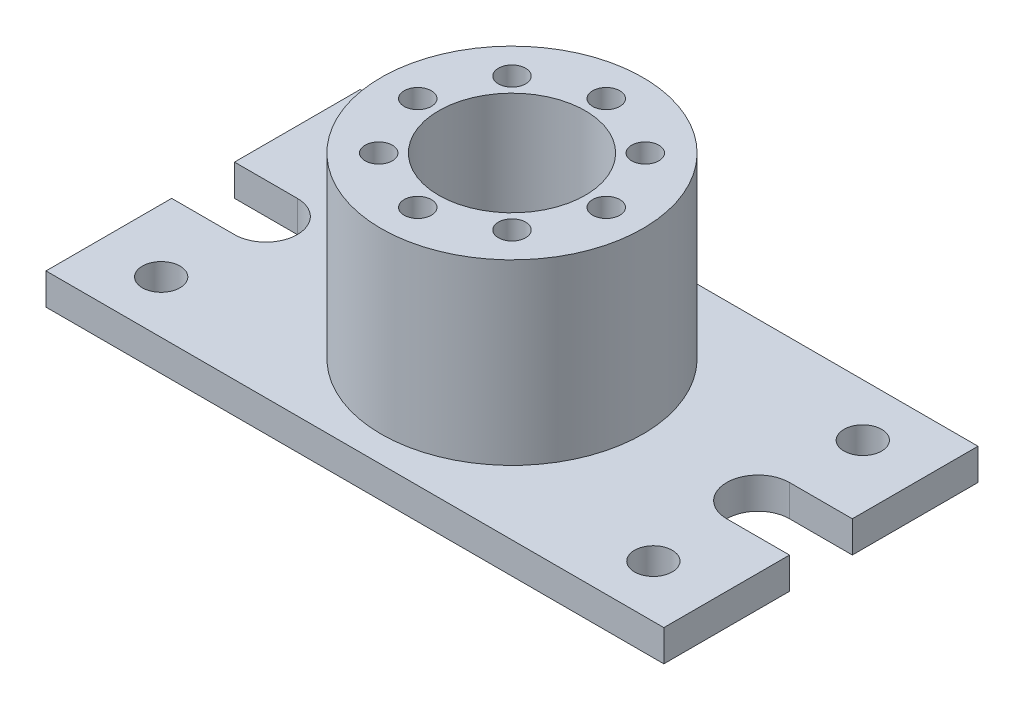
from build123d import *

# Parameters (mm, degrees)
SKETCH1_R           = 9
BOSS_EXTRUDE1_DEPTH = 15
SKETCH2_R           = 62.5
BOSS_EXTRUDE2_DEPTH = 85
SKETCH3_R           = 35
CUT_EXTRUDE1_DEPTH  = 101
SKETCH4_R           = 6.5
CUT_EXTRUDE2_DEPTH  = 50


with BuildPart() as part:
    # Sketch1 → Boss-Extrude1 (new body)
    with BuildSketch(Plane(origin=(0, 0, 0), x_dir=(1, 0, 0), z_dir=(0, 1, 0))):
        with BuildLine():
            Line((-147.5, -15), (-147.5, -75))
            Line((-147.5, -75), (147.5, -75))
            Line((147.5, -75), (147.5, -15))
            Line((147.5, -15), (117.5, -15))
            ThreePointArc((117.5, -15), (102.5, 0), (117.5, 15))
            Line((117.5, 15), (147.5, 15))
            Line((147.5, 15), (147.5, 75))
            Line((147.5, 75), (-147.5, 75))
            Line((-147.5, 75), (-147.5, 15))
            Line((-147.5, 15), (-117.5, 15))
            ThreePointArc((-117.5, 15), (-102.5, 0), (-117.5, -15))
            Line((-117.5, -15), (-147.5, -15))
        make_face()
        with Locations((-117.5, -50)):
            Circle(SKETCH1_R, mode=Mode.SUBTRACT)
        with Locations((117.5, -50)):
            Circle(SKETCH1_R, mode=Mode.SUBTRACT)
        with Locations((-117.5, 50)):
            Circle(SKETCH1_R, mode=Mode.SUBTRACT)
        with Locations((117.5, 50)):
            Circle(SKETCH1_R, mode=Mode.SUBTRACT)
    extrude(amount=BOSS_EXTRUDE1_DEPTH)

    # Sketch2 → Boss-Extrude2 (add)
    with BuildSketch(Plane(origin=(0, 15, 0), x_dir=(1, 0, 0), z_dir=(0, 1, 0))):
        Circle(SKETCH2_R)
    extrude(amount=BOSS_EXTRUDE2_DEPTH)

    # Sketch3 → Cut-Extrude1 (cut, through all)
    with BuildSketch(Plane(origin=(0, 100, 0), x_dir=(1, 0, 0), z_dir=(0, 1, 0))):
        Circle(SKETCH3_R)
    extrude(amount=-CUT_EXTRUDE1_DEPTH, mode=Mode.SUBTRACT)

    # Sketch4 → Cut-Extrude2 (cut)
    with BuildSketch(Plane(origin=(0, 100, 0), x_dir=(1, 0, 0), z_dir=(0, 1, 0))):
        with Locations((-45, 0)):
            Circle(SKETCH4_R)
        with Locations((-31.819805153, 31.819805153)):
            Circle(SKETCH4_R)
        with Locations((0, 45)):
            Circle(SKETCH4_R)
        with Locations((31.819805153, 31.819805153)):
            Circle(SKETCH4_R)
        with Locations((45, 0)):
            Circle(SKETCH4_R)
        with Locations((31.819805153, -31.819805153)):
            Circle(SKETCH4_R)
        with Locations((0, -45)):
            Circle(SKETCH4_R)
        with Locations((-31.819805153, -31.819805153)):
            Circle(SKETCH4_R)
    extrude(amount=-CUT_EXTRUDE2_DEPTH, mode=Mode.SUBTRACT)


solid = part.part
